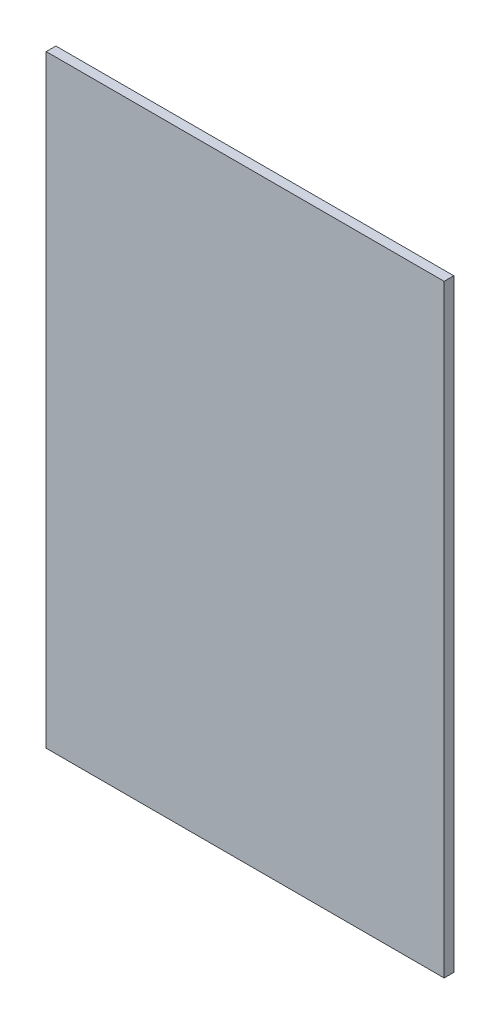
from build123d import *

# Parameters (mm, degrees)
SKETCH1_W           = 83.764
SKETCH1_H           = 127
BOSS_EXTRUDE1_DEPTH = 2.032


with BuildPart() as part:
    # Sketch1 → Boss-Extrude1 (new body)
    with BuildSketch(Plane.XY):
        with Locations((43.914, 65.532)):
            Rectangle(SKETCH1_W, SKETCH1_H)
    extrude(amount=-BOSS_EXTRUDE1_DEPTH)


solid = part.part
